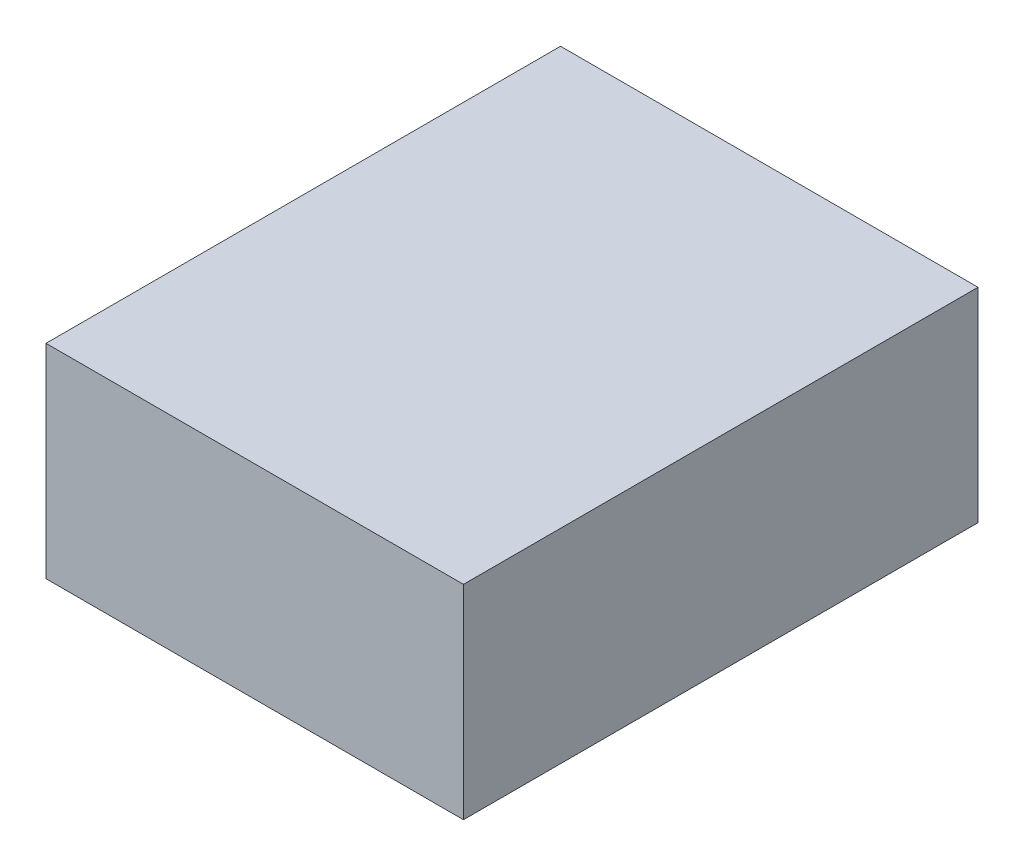
from build123d import *

# Parameters (mm, degrees)
SKETCH1_W           = 43
SKETCH1_H           = 53
BOSS_EXTRUDE1_DEPTH = 21


with BuildPart() as part:
    # Sketch1 → Boss-Extrude1 (new body)
    with BuildSketch(Plane(origin=(0, 0, 0), x_dir=(1, 0, 0), z_dir=(0, 1, 0))):
        with Locations((21.5, 26.5)):
            Rectangle(SKETCH1_W, SKETCH1_H)
    extrude(amount=BOSS_EXTRUDE1_DEPTH)


solid = part.part
